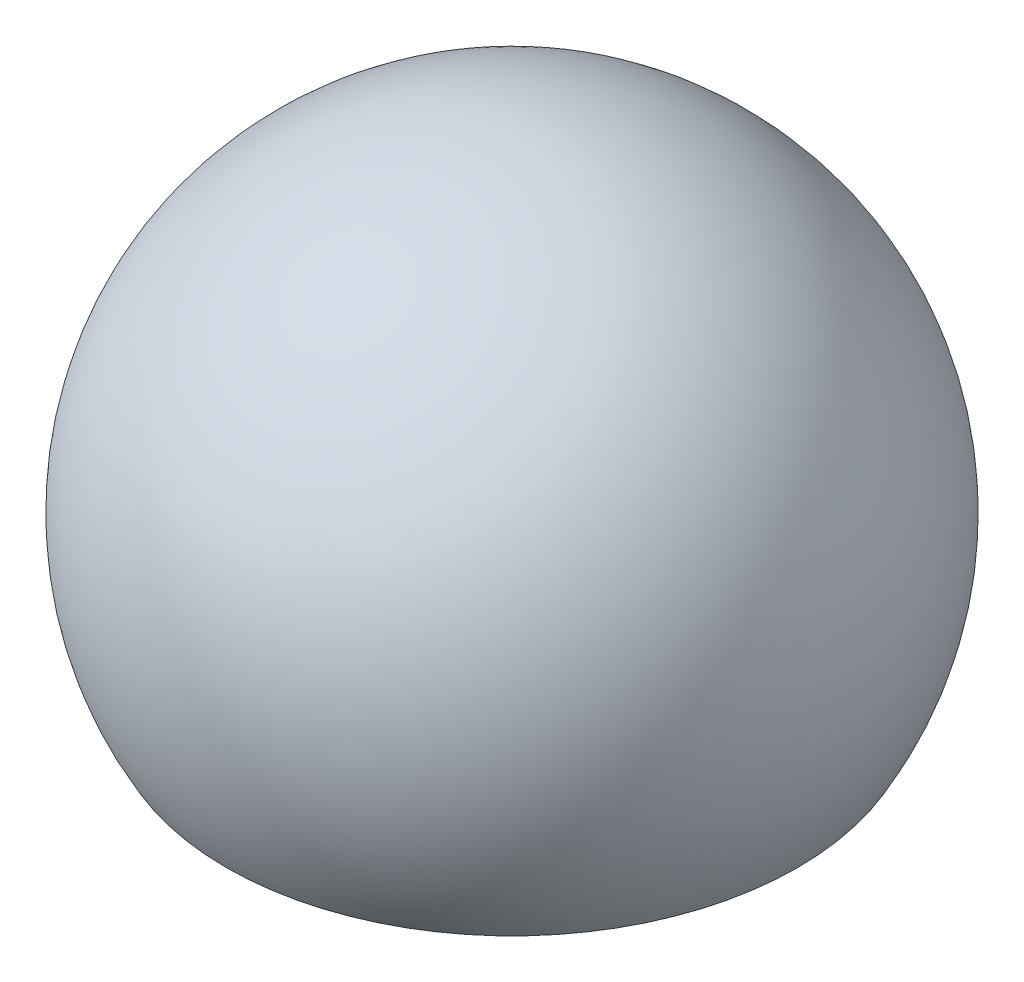
from build123d import *

# Parameters (mm, degrees)
TRUNCATED_BALL_DEPTH      = 13.7
TRUNCATED_BALL_DEPTH_BACK = 13.7
SKETCH3_R                 = 8.4582
RECESSED_DEPTH            = 0.127
SKETCH4_R                 = 2.54
THREADED_DEPTH            = 6.35
CHAMFER2_SIZE             = 0.635


with BuildPart() as part:
    # Sketch1 → Complete_Ball (revolve)
    with BuildSketch(Plane.XY):
        with BuildLine():
            Line((0, 12.7), (0, -12.7))
            ThreePointArc((0, -12.7), (12.7, 0), (0, 12.7))
        make_face()
    revolve(axis=Axis((0, 13.6525, 0), (0, -1, 0)))

    # Sketch2 → Truncated_ball (cut, two sides)
    with BuildSketch(Plane.XY) as truncated_ball_sk:
        with BuildLine():
            Line((-10.998522628, -6.35), (10.998522628, -6.35))
            ThreePointArc((10.998522628, -6.35), (0, -12.7), (-10.998522628, -6.35))
        make_face()
    extrude(amount=TRUNCATED_BALL_DEPTH, mode=Mode.SUBTRACT)
    extrude(truncated_ball_sk.sketch, amount=-TRUNCATED_BALL_DEPTH_BACK, mode=Mode.SUBTRACT)

    # Sketch3 → Recessed (cut)
    with BuildSketch(Plane.XZ.offset(6.35)):
        with Locations(Location((0, 0, 0), (0, 0, 270))):  # turned: the seam where the file's is
            Circle(SKETCH3_R)
    extrude(amount=-RECESSED_DEPTH, mode=Mode.SUBTRACT)

    # Sketch4 → Threaded (cut)
    with BuildSketch(Plane.XZ.offset(6.223)):
        with Locations(Location((0, 0, 0), (0, 0, 270))):  # turned: the seam where the file's is
            Circle(SKETCH4_R)
    extrude(amount=-THREADED_DEPTH, mode=Mode.SUBTRACT)

    # Chamfer2
    chamfer2_edges = [part.edges().sort_by_distance(p)[0] for p in [
        (0, -6.223, 2.54),
    ]]
    chamfer(chamfer2_edges, length=CHAMFER2_SIZE)


solid = part.part
